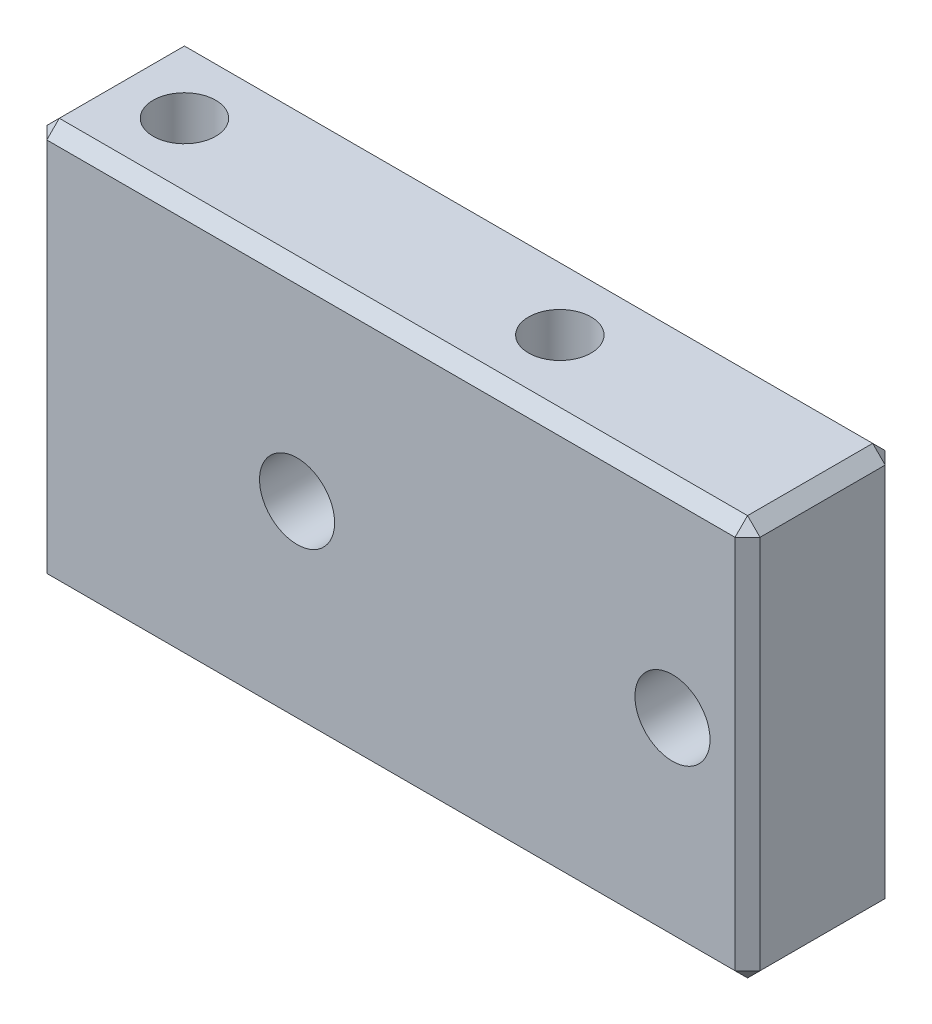
from build123d import *

# Parameters (mm, degrees)
SKETCH_2_W         = 28.5
SKETCH_2_H         = 16
SKETCH_2_R         = 1.5
EXTRUDE_1_DEPTH    = 3
HOLE_WIZARD_M3_2_D = 2.5
CHAMFER_1_SIZE     = 0.5


with BuildPart() as part:
    # 草图2 → 凸台-拉伸1 (new body, symmetric)
    with BuildSketch(Plane.XY):
        with Locations((-11.25, 0)):
            Rectangle(SKETCH_2_W, SKETCH_2_H)
        with Locations((-15, 0)):
            Circle(SKETCH_2_R, mode=Mode.SUBTRACT)
        Circle(SKETCH_2_R, mode=Mode.SUBTRACT)
    extrude(amount=EXTRUDE_1_DEPTH, both=True)

    # M3 螺纹孔2 (through all)
    with Locations(Plane(origin=(0, 8, 0), x_dir=(1, 0, 0), z_dir=(0, 1, 0))):
        with Locations((-7.5, 0), (-22.5, 0)):
            Hole(HOLE_WIZARD_M3_2_D / 2)

    # 倒角1
    chamfer_1_edges = [part.edges().sort_by_distance(p)[0] for p in [
        (-11.25, -8, 3),
        (3, 0, 3),
        (-11.25, 8, 3),
        (3, 0, -3),
        (-11.25, -8, -3),
        (-25.5, 0, -3),
        (-11.25, 8, -3),
        (-25.5, 0, 3),
        (3, 8, 0),
        (3, -8, 0),
        (-25.5, -8, 0),
        (-25.5, 8, 0),
    ]]
    chamfer(chamfer_1_edges, length=CHAMFER_1_SIZE)


solid = part.part
